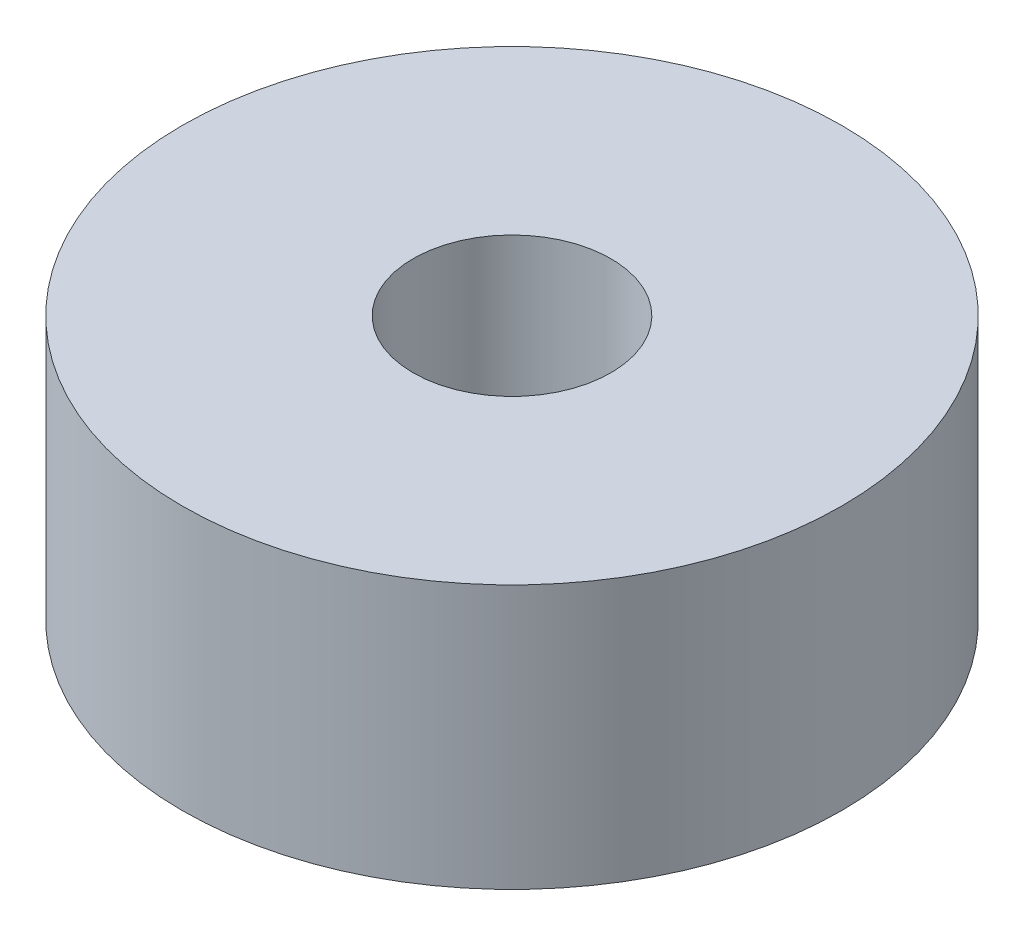
from build123d import *

# Parameters (mm, degrees)
SKETCH1_R           = 5
SKETCH1_R_2         = 1.5
BOSS_EXTRUDE1_DEPTH = 4


with BuildPart() as part:
    # Sketch1 → Boss-Extrude1 (new body)
    with BuildSketch(Plane(origin=(0, 0, 0), x_dir=(1, 0, 0), z_dir=(0, 1, 0))):
        Circle(SKETCH1_R)
        Circle(SKETCH1_R_2, mode=Mode.SUBTRACT)
    extrude(amount=BOSS_EXTRUDE1_DEPTH)


solid = part.part
